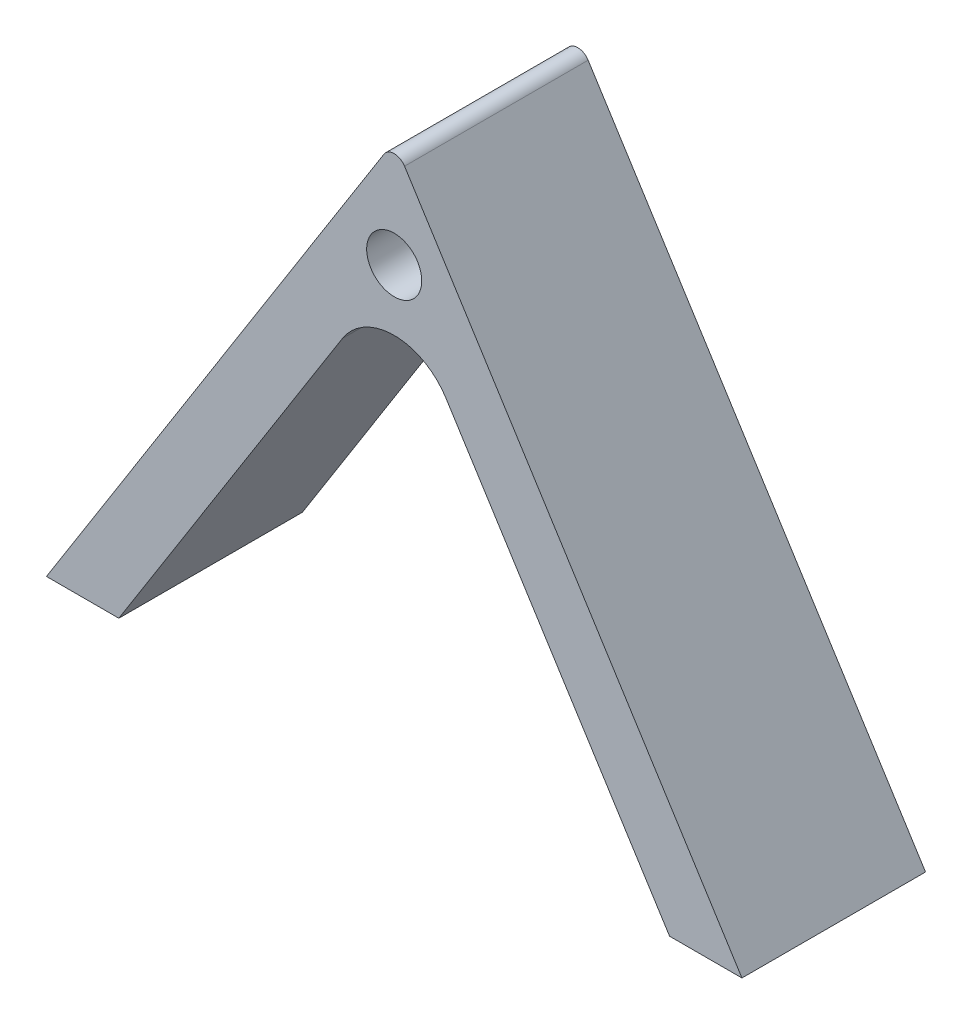
from build123d import *

# Parameters (mm, degrees)
BOSS_EXTRUDE1_DEPTH = 30
FILLET1_R           = 2
FILLET2_R           = 10
SKETCH2_R           = 4.5
CUT_EXTRUDE1_DEPTH  = 31


with BuildPart() as part:
    # Sketch1 → Boss-Extrude1 (new body)
    with BuildSketch(Plane.XY):
        Polygon((-56.826553722, 0), (0, 90), (56.826553722, 0), (45, 0), (0, 71.26949876), (-45, 0), align=None)
    extrude(amount=BOSS_EXTRUDE1_DEPTH)

    # Fillet1
    fillet1_edges = [part.edges().sort_by_distance(p)[0] for p in [
        (0, 90, 15),
    ]]
    fillet(fillet1_edges, radius=FILLET1_R)

    # Fillet2
    fillet2_edges = [part.edges().sort_by_distance(p)[0] for p in [
        (0, 71.26949876, 15),
    ]]
    fillet(fillet2_edges, radius=FILLET2_R)

    # Sketch2 → Cut-Extrude1 (cut, through all)
    with BuildSketch(Plane.XY.offset(30)):
        with Locations((0, 72.5)):
            Circle(SKETCH2_R)
    extrude(amount=-CUT_EXTRUDE1_DEPTH, mode=Mode.SUBTRACT)


solid = part.part
